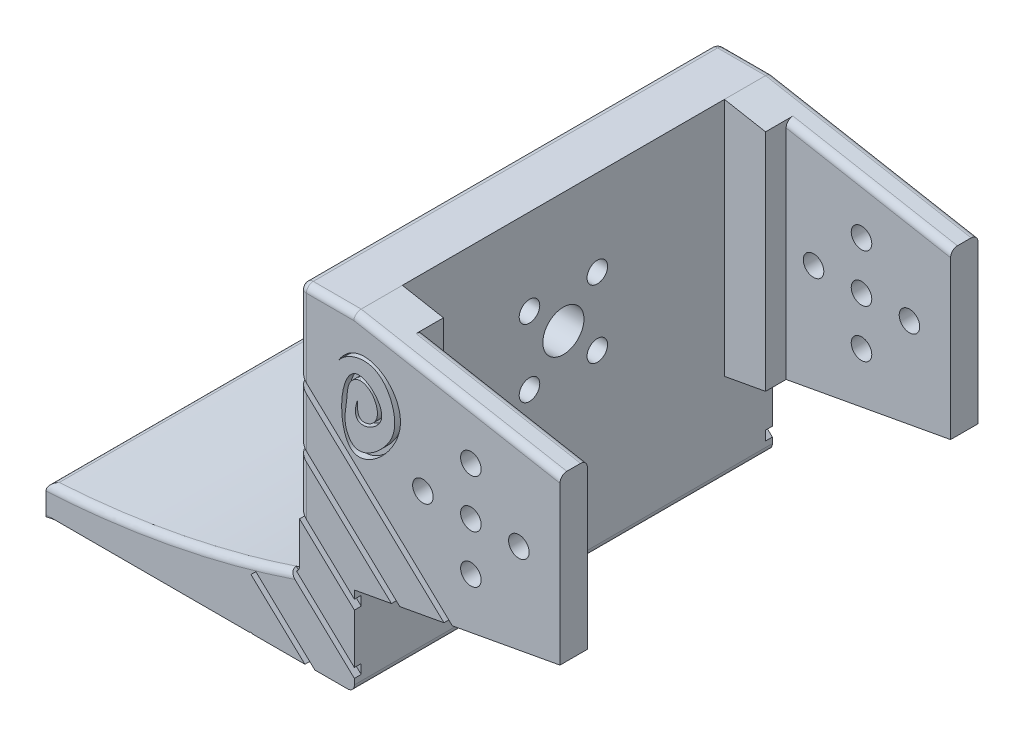
from build123d import *

# Parameters (mm, degrees)
SKETCH_1_W               = 56
SKETCH_1_H               = 61
EXTRUDE_1_DEPTH          = 4
SKETCH_2_W               = 4
SKETCH_2_H               = 61
EXTRUDE_2_DEPTH          = 61
SKETCH_4_W               = 15
SKETCH_4_H               = 61
CUT_EXTRUDE_2_DEPTH      = 61
EXTRUDE_4_DEPTH          = 61
SKETCH_9_W               = 61
SKETCH_9_H               = 65
EXTRUDE_5_DEPTH          = 6
EXTRUDE_9_DEPTH          = 0.25
EXTRUDE_10_DEPTH         = 0.25
EXTRUDE_11_DEPTH         = 0.25
EXTRUDE_12_DEPTH         = 0.25
EXTRUDE_12_TAPER         = 25
EXTRUDE_13_DEPTH         = 0.5
EXTRUDE_13_TAPER         = 63
SKETCH_31_W              = 61
SKETCH_31_H              = 65
CUT_EXTRUDE_3_DEPTH      = 2
SKETCH_32_W              = 8
SKETCH_32_H              = 17
CUT_EXTRUDE_4_DEPTH      = 28
CUT_EXTRUDE_4_DEPTH_BACK = 100
SKETCH_3_R               = 3
SKETCH_3_R_2             = 1.5
CUT_EXTRUDE_5_DEPTH      = 23
CUT_EXTRUDE_5_DEPTH_BACK = 74
SKETCH_33_R              = 1.5
EXTRUDE_14_DEPTH         = 7
CUT_EXTRUDE_6_DEPTH      = 3
SKETCH_35_W              = 16
SKETCH_35_H              = 1.5
CUT_EXTRUDE_7_DEPTH      = 2
CUT_EXTRUDE_9_DEPTH      = 1
CUT_EXTRUDE_10_DEPTH     = 1
FILLET_1_R               = 1


with BuildPart() as part:
    # 草图1 → 凸台-拉伸1 (new body)
    with BuildSketch(Plane(origin=(0, 0, 0), x_dir=(1, 0, 0), z_dir=(0, 1, 0))):
        Rectangle(SKETCH_1_W, SKETCH_1_H)
    extrude(amount=EXTRUDE_1_DEPTH)

    # 草图2 → 凸台-拉伸2 (add)
    with BuildSketch(Plane(origin=(0, 4, 0), x_dir=(1, 0, 0), z_dir=(0, 1, 0))):
        with Locations((26, 0)):
            Rectangle(SKETCH_2_W, SKETCH_2_H)
    extrude(amount=EXTRUDE_2_DEPTH)

    # 草图4 → 切除-拉伸2 (cut)
    with BuildSketch(Plane.XZ):
        with Locations((-20.5, 0)):
            Rectangle(SKETCH_4_W, SKETCH_4_H)
    extrude(amount=-CUT_EXTRUDE_2_DEPTH, mode=Mode.SUBTRACT)

    # 草图8 → 凸台-拉伸4 (add)
    with BuildSketch(Plane(origin=(0, 0, -30.5), x_dir=(-1, 0, 0), z_dir=(0, 0, -1))):
        with BuildLine():
            Line((-24, 11.278113167), (-24, 4))
            Line((-24, 4), (13, 4))
            add(Edge.make_bspline(
                [(13, 4), (-6.090064975, 5.064159428), (-24, 11.278113167)],
                knots=[0, 0, 0, 1, 1, 1], degree=2))
        make_face()
    extrude(amount=-EXTRUDE_4_DEPTH)

    # 草图9 → 凸台-拉伸5 (add)
    with BuildSketch(Plane(origin=(28, 0, 0), x_dir=(0, 0, -1), z_dir=(1, 0, 0))):
        with Locations((0, 32.5)):
            Rectangle(SKETCH_9_W, SKETCH_9_H)
    extrude(amount=EXTRUDE_5_DEPTH)

    # 草图26 → 凸台-拉伸9 (add)
    with BuildSketch(Plane.XZ):
        Polygon((28, -20), (28, 20), (-13, 30.5), (-13, -30.5), align=None)
    extrude(amount=EXTRUDE_9_DEPTH)

    # 草图27 → 凸台-拉伸10 (add)
    with BuildSketch(Plane.XZ.offset(0.25)):
        Polygon((-13, 25.5), (23, 18), (23, -18), (-13, -25.5), align=None)
    extrude(amount=EXTRUDE_10_DEPTH)

    # 草图28 → 凸台-拉伸11 (add)
    with BuildSketch(Plane.XZ.offset(0.5)):
        Polygon((18, 16), (-13, 20.5), (-13, -20.5), (18, -16), align=None)
    extrude(amount=EXTRUDE_11_DEPTH)

    # 草图29 → 凸台-拉伸12 (add)
    with BuildSketch(Plane.XZ.offset(0.75)):
        Polygon((13, 14), (-13, 15.5), (-13, -15.5), (13, -14), align=None)
    extrude(amount=EXTRUDE_12_DEPTH, taper=EXTRUDE_12_TAPER)

    # 草图30 → 凸台-拉伸13 (add)
    with BuildSketch(Plane.XZ.offset(1)):
        Polygon((8, 8), (-12.883423085, 10.5), (-12.883423085, -10.5), (8, -8), align=None)
    extrude(amount=EXTRUDE_13_DEPTH, taper=EXTRUDE_13_TAPER)

    # 草图31 → 切除-拉伸3 (cut)
    with BuildSketch(Plane(origin=(34, 0, 0), x_dir=(0, 0, -1), z_dir=(1, 0, 0))):
        with Locations((0, 32.5)):
            Rectangle(SKETCH_31_W, SKETCH_31_H)
    extrude(amount=-CUT_EXTRUDE_3_DEPTH, mode=Mode.SUBTRACT)

    # 草图32 → 切除-拉伸4 (cut, two sides)
    with BuildSketch(Plane(origin=(0, 0, -30.5), x_dir=(-1, 0, 0), z_dir=(0, 0, -1))) as cut_extrude_4_sk:
        Polygon((-37.995699382, 67.001937784), (-32, 48), (-32, 65), (-24, 65), (-24, 48), (-19.335612367, 48), (-19.335612367, 67.737310671), align=None)
        with Locations((-28, 56.5)):
            Rectangle(SKETCH_32_W, SKETCH_32_H)
    extrude(amount=CUT_EXTRUDE_4_DEPTH, mode=Mode.SUBTRACT)
    extrude(cut_extrude_4_sk.sketch, amount=-CUT_EXTRUDE_4_DEPTH_BACK, mode=Mode.SUBTRACT)

    # 草图3 → 切除-拉伸5 (cut, two sides)
    with BuildSketch(Plane(origin=(28, 0, 0), x_dir=(0, 0, -1), z_dir=(1, 0, 0))) as cut_extrude_5_sk:
        with Locations((0, 30.5)):
            Circle(SKETCH_3_R)
        with Locations((4.949747468, 35.449747468)):
            Circle(SKETCH_3_R_2)
        with Locations((4.949747468, 25.550252532)):
            Circle(SKETCH_3_R_2)
        with Locations((-4.949747468, 25.550252532)):
            Circle(SKETCH_3_R_2)
        with Locations((-4.949747468, 35.449747468)):
            Circle(SKETCH_3_R_2)
    extrude(amount=CUT_EXTRUDE_5_DEPTH, mode=Mode.SUBTRACT)
    extrude(cut_extrude_5_sk.sketch, amount=-CUT_EXTRUDE_5_DEPTH_BACK, mode=Mode.SUBTRACT)

    # 草图33 → 凸台-拉伸14 (add)
    with BuildSketch(Plane(origin=(0, 0, -30.5), x_dir=(-1, 0, 0), z_dir=(0, 0, -1))):
        Polygon((-32, 33.5), (-32, 48), (-62, 42.5), (-62, 30.5), (-62, 18.5), (-32, 13), (-32, 27.5), align=None)
        with Locations((-49, 30.5)):
            Circle(SKETCH_33_R, mode=Mode.SUBTRACT)
        with Locations((-49, 37.5)):
            Circle(SKETCH_33_R, mode=Mode.SUBTRACT)
        with Locations((-42, 30.5)):
            Circle(SKETCH_33_R, mode=Mode.SUBTRACT)
        with Locations((-49, 23.5)):
            Circle(SKETCH_33_R, mode=Mode.SUBTRACT)
        with Locations((-56, 30.5)):
            Circle(SKETCH_33_R, mode=Mode.SUBTRACT)
    extrude_14 = extrude(amount=-EXTRUDE_14_DEPTH)

    # 草图34 → 切除-拉伸6 (cut)
    with BuildSketch(Plane.XY.offset(-23.5)):
        Polygon((38, 48), (38, 9.310266784), (72.731828602, 14.568962173), (66.940607098, 48), align=None)
    cut_extrude_6 = extrude(amount=-CUT_EXTRUDE_6_DEPTH, mode=Mode.SUBTRACT)

    # 镜向1: 凸台-拉伸14, 切除-拉伸6 across plane
    add(extrude_14.mirror(Plane.XY))
    add(cut_extrude_6.mirror(Plane.XY), mode=Mode.SUBTRACT)

    # 草图35 → 切除-拉伸7 (cut)
    with BuildSketch(Plane.XZ.offset(1.5)):
        with Locations((-3.902117833, 10.144214029)):
            Rectangle(SKETCH_35_W, SKETCH_35_H)
        with Locations((-3.902117833, 5.144214029)):
            Rectangle(SKETCH_35_W, SKETCH_35_H)
        with Locations((-3.902117833, 0.144214029)):
            Rectangle(SKETCH_35_W, SKETCH_35_H)
        with Locations((-3.902117833, -4.855785971)):
            Rectangle(SKETCH_35_W, SKETCH_35_H)
        with Locations((-3.902117833, -9.855785971)):
            Rectangle(SKETCH_35_W, SKETCH_35_H)
    extrude(amount=-CUT_EXTRUDE_7_DEPTH, mode=Mode.SUBTRACT)

    # 草图38 → 切除-拉伸9 (cut)
    with BuildSketch(Plane(origin=(0, 0, -30.5), x_dir=(-1, 0, 0), z_dir=(0, 0, -1))):
        with BuildLine():
            add(Edge.make_bspline(
                [(-29.631516561, 40.785434798), (-30.703651137, 42.312155514), (-35.732104949, 43.966497559), (-38.609375665, 37.505487975), (-36.790220481, 33.046206868), (-32.372806589, 29.698781128), (-30.284504048, 33.482774188), (-30.99516542, 36.170447953), (-30.95735915, 38.990566046), (-32.687658759, 40.066195255), (-34.384768942, 39.529136907), (-35.321385311, 38.054005752), (-35.436411333, 36.265330563), (-34.517020913, 34.958820088), (-32.266988538, 34.738680488), (-32.451388299, 36.798297704), (-32.458412841, 37.196700541)],
                knots=[0.022990424, 0.022990424, 0.022990424, 0.022990424, 0.156640138, 0.310916644, 0.396308587, 0.522088321, 0.573859013, 0.656803832, 0.727076996, 0.75581331, 0.789106287, 0.844334069, 0.870788831, 0.915542551, 0.946792777, 1, 1, 1, 1], degree=3))
            add(Edge.make_bspline(
                [(-29.631516561, 40.785434798), (-32.71876285, 46.036695877), (-44.228409263, 38.922502722), (-29.051302934, 24.419152789), (-29.863359795, 44.761606635), (-39.070163039, 35.587673783), (-30.94056988, 32.943384783), (-32.458412841, 37.196700541)],
                knots=[0.014478534, 0.014478534, 0.014478534, 0.014478534, 0.306304988, 0.518453322, 0.743260392, 0.858590078, 1, 1, 1, 1], degree=3))
        make_face()
    cut_extrude_9 = extrude(amount=-CUT_EXTRUDE_9_DEPTH, mode=Mode.SUBTRACT)

    # 草图39 → 切除-拉伸10 (cut)
    with BuildSketch(Plane(origin=(0, 0, -30.5), x_dir=(-1, 0, 0), z_dir=(0, 0, -1))):
        Polygon((-20.402885872, 39.999966581), (-52.055100898, 10.195469691), (-51.369563304, 9.467432462), (-19.697462771, 39.290654029), align=None)
        Polygon((-19.70563993, 32.030408996), (-51.357854956, 2.225912106), (-50.672317362, 1.497874877), (-19.000216829, 31.321096445), align=None)
        Polygon((-19.008393988, 24.060851412), (-50.660609014, -5.743645478), (-49.97507142, -6.471682708), (-18.302970888, 23.35153886), align=None)
        Polygon((-18.311148046, 16.091293827), (-49.963363072, -13.713203063), (-49.277825478, -14.441240292), (-17.605724946, 15.381981275), align=None)
        Polygon((-17.613902104, 8.121736242), (-49.26611713, -21.682760648), (-48.580579536, -22.410797877), (-16.908479004, 7.412423691), align=None)
        Polygon((-16.916656162, 0.152178657), (-48.568871188, -29.652318233), (-47.883333594, -30.380355462), (-16.211233062, -0.557133894), align=None)
        Polygon((-16.21941022, -7.817378927), (-47.871625246, -37.621875817), (-47.186087652, -38.349913047), (-15.51398712, -8.526691479), align=None)
        Polygon((-15.522164278, -15.786936512), (-47.174379304, -45.591433402), (-46.48884171, -46.319470631), (-14.816741178, -16.496249064), align=None)
        Polygon((-14.824918336, -23.756494097), (-46.477133362, -53.560990987), (-45.791595768, -54.289028216), (-14.119495236, -24.465806648), align=None)
    cut_extrude_10 = extrude(amount=-CUT_EXTRUDE_10_DEPTH, mode=Mode.SUBTRACT)

    # 镜向2: 切除-拉伸9, 切除-拉伸10 across plane
    add(cut_extrude_9.mirror(Plane.XY), mode=Mode.SUBTRACT)
    add(cut_extrude_10.mirror(Plane.XY), mode=Mode.SUBTRACT)

    # 圆角1
    fillet_1_edges = [part.edges().sort_by_distance(p)[0] for p in [
        (47, 45.25, 30.5),
        (50, 44.7, 26.5),
        (50, 44.7, -26.5),
        (47, 45.25, -30.5),
        (28, 48, 30.5),
        (28, 48, -30.5),
        (24, 48, 0),
        (24, 42.306418136, 30.5),
        (24, 42.306418136, -30.5),
        (24, 31.613007531, -30.5),
        (24, 31.613007531, 30.5),
        (24, 22.986906179, 30.5),
        (24, 22.986906179, -30.5),
        (32, 0, 0),
        (-13, 4, 0),
        (24, 11.278113167, 0),
        (4.979561721, 6.193810816, 30.5),
        (4.979561721, 6.193810816, -30.5),
    ]]
    fillet(fillet_1_edges, radius=FILLET_1_R)


solid = part.part
